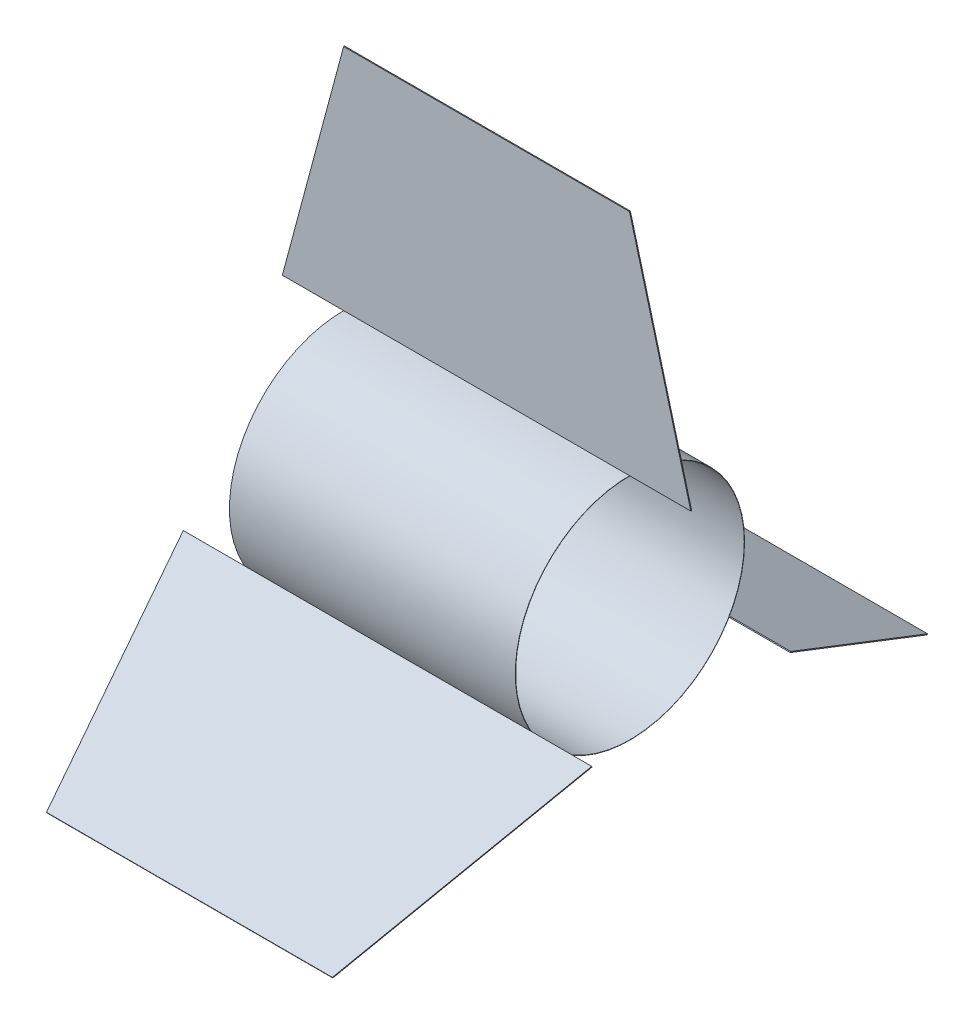
from build123d import *

# Parameters (mm, degrees)
SKETCH1_R           = 101.854
SKETCH1_R_2         = 101.6
EXTRUDE_THIN1_DEPTH = 254
BOSS_EXTRUDE1_DEPTH = 0.396875
CIRPATTERN2_COUNT   = 3


with BuildPart() as part:
    # Sketch1 → Extrude-Thin1 (new body)
    with BuildSketch(Plane(origin=(0, 0, 0), x_dir=(0, 0, -1), z_dir=(1, 0, 0))):
        Circle(SKETCH1_R)
        Circle(SKETCH1_R_2, mode=Mode.SUBTRACT)
    extrude(amount=EXTRUDE_THIN1_DEPTH)


with BuildPart() as body_2:
    # Sketch2 → Boss-Extrude1 (new, symmetric)
    with BuildSketch(Plane.XY):
        Polygon((308.447275902, 101.854), (254, 305.054), (0, 305.054), (-54.447275902, 101.854), align=None)
    extrude(amount=BOSS_EXTRUDE1_DEPTH, both=True)


with BuildPart() as cirpattern2_1:
    # CirPattern2: pattern copy
    add(body_2.part.rotate(Axis((-33.196859496, 0, 0), (1, 0, 0)), 1 * 360 / CIRPATTERN2_COUNT))


with BuildPart() as cirpattern2_2:
    # CirPattern2: pattern copy
    add(body_2.part.rotate(Axis((-33.196859496, 0, 0), (1, 0, 0)), 2 * 360 / CIRPATTERN2_COUNT))


solid = Compound([part.part, body_2.part, cirpattern2_1.part, cirpattern2_2.part])
